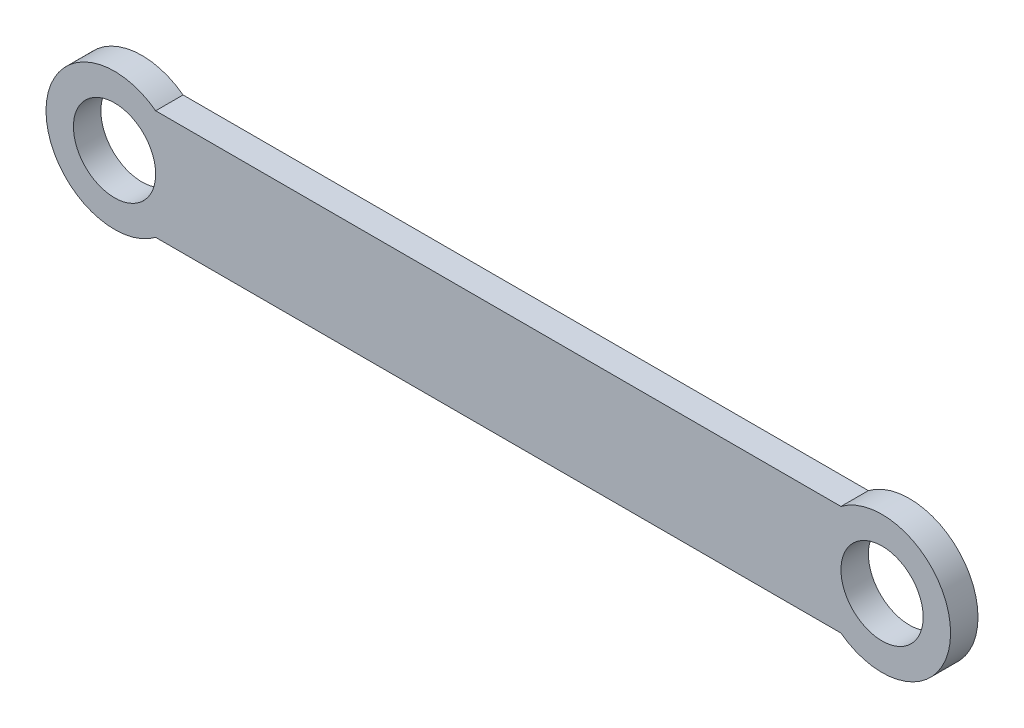
from build123d import *

# Parameters (mm, degrees)
SKETCH_1_R      = 1.5
EXTRUDE_1_DEPTH = 1


with BuildPart() as part:
    # 草图1 → 凸台-拉伸1 (new body)
    with BuildSketch(Plane.XY):
        with BuildLine():
            Line((22.589755848, 2.198128931), (47.589755848, 2.198128931))
            ThreePointArc((47.589755848, 2.198128931), (51.589755848, 0.198128931), (47.589755848, -1.801871069))
            Line((47.589755848, -1.801871069), (22.589755848, -1.801871069))
            ThreePointArc((22.589755848, -1.801871069), (18.589755848, 0.198128931), (22.589755848, 2.198128931))
        make_face()
        with Locations((49.089755848, 0.198128931)):
            Circle(SKETCH_1_R, mode=Mode.SUBTRACT)
        with Locations((21.089755848, 0.198128931)):
            Circle(SKETCH_1_R, mode=Mode.SUBTRACT)
    extrude(amount=EXTRUDE_1_DEPTH)


solid = part.part
